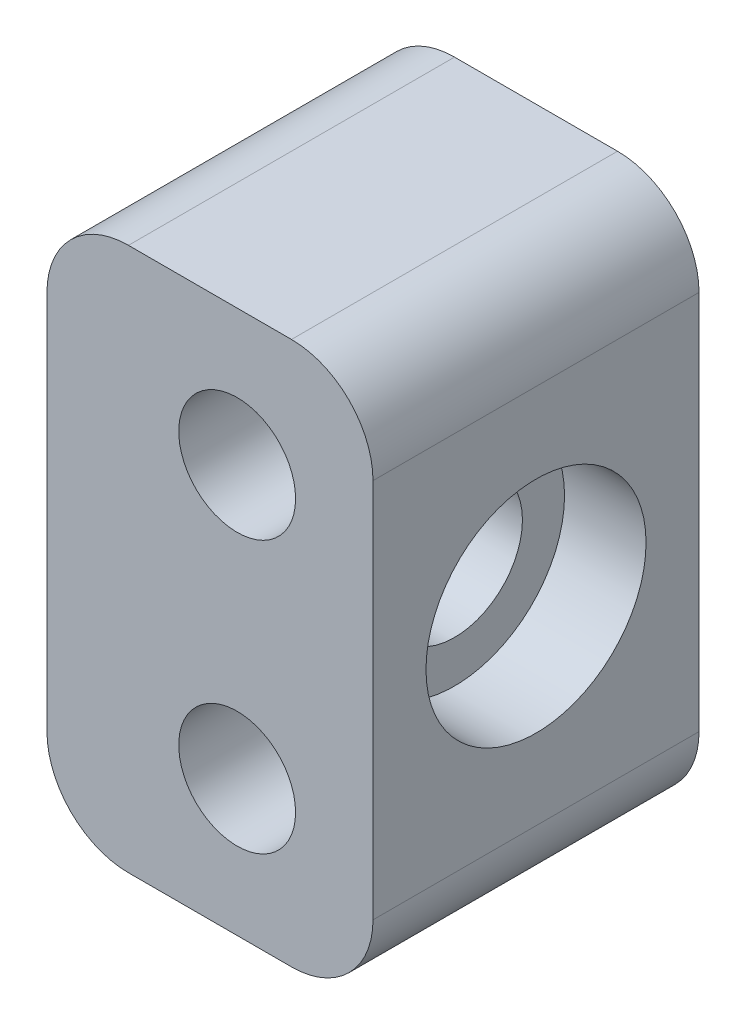
from build123d import *

# Parameters (mm, degrees)
SKETCH1_R           = 2.15
BOSS_EXTRUDE1_DEPTH = 12
SKETCH2_W           = 7.5
SKETCH2_H           = 7.5
SKETCH2_R           = 2.5
CUT_EXTRUDE1_DEPTH  = 5
SKETCH2_2_R         = 2.5
CUT_EXTRUDE2_DEPTH  = 20.697715604
SKETCH3_R           = 4.05
CUT_EXTRUDE3_DEPTH  = 3


with BuildPart() as part:
    # Sketch1 → Boss-Extrude1 (new body)
    with BuildSketch(Plane.XY):
        with BuildLine():
            Line((-4, -10), (2, -10))
            ThreePointArc((2, -10), (4.121320344, -9.121320344), (5, -7))
            Line((5, -7), (5, 7))
            ThreePointArc((5, 7), (4.121320344, 9.121320344), (2, 10))
            Line((2, 10), (-4, 10))
            ThreePointArc((-4, 10), (-6.121320344, 9.121320344), (-7, 7))
            Line((-7, 7), (-7, -7))
            ThreePointArc((-7, -7), (-6.121320344, -9.121320344), (-4, -10))
        make_face()
        with Locations((0, 5)):
            Circle(SKETCH1_R, mode=Mode.SUBTRACT)
        with Locations((0, -5)):
            Circle(SKETCH1_R, mode=Mode.SUBTRACT)
    extrude(amount=BOSS_EXTRUDE1_DEPTH)

    # Sketch2 → Cut-Extrude1 (cut)
    with BuildSketch(Plane.ZY.offset(7)):
        with Locations((6, 0)):
            Rectangle(SKETCH2_W, SKETCH2_H)
        with Locations((6, 0)):
            Circle(SKETCH2_R, mode=Mode.SUBTRACT)
    extrude(amount=-CUT_EXTRUDE1_DEPTH, mode=Mode.SUBTRACT)

    # Sketch2_2 → Cut-Extrude2 (cut, through all)
    with BuildSketch(Plane.ZY.offset(7)):
        with Locations((6, 0)):
            Circle(SKETCH2_2_R)
    extrude(amount=-CUT_EXTRUDE2_DEPTH, mode=Mode.SUBTRACT)

    # Sketch3 → Cut-Extrude3 (cut)
    with BuildSketch(Plane(origin=(5, 0, 0), x_dir=(0, 0, -1), z_dir=(1, 0, 0))):
        with Locations((-6, 0)):
            Circle(SKETCH3_R)
    extrude(amount=-CUT_EXTRUDE3_DEPTH, mode=Mode.SUBTRACT)


solid = part.part
